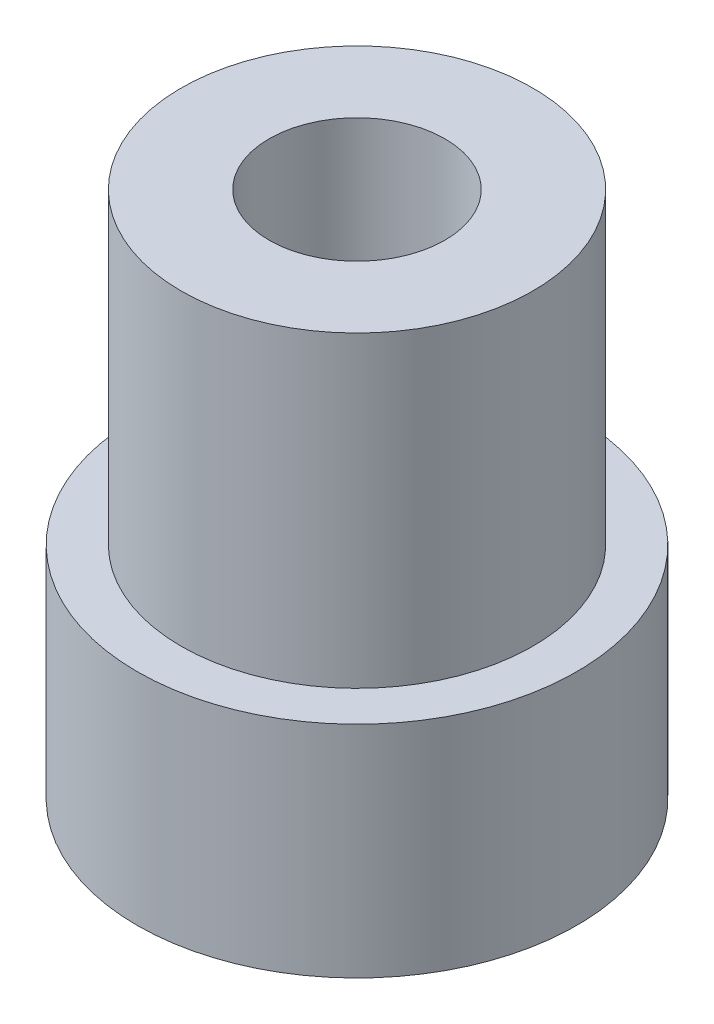
from build123d import *

# Parameters (mm, degrees)
SKETCH2_R           = 4
BOSS_EXTRUDE1_DEPTH = 7
SKETCH3_R           = 5
BOSS_EXTRUDE2_DEPTH = 5
SKETCH4_R           = 1.65
CUT_EXTRUDE1_DEPTH  = 12
SKETCH5_R           = 2
CUT_EXTRUDE2_DEPTH  = 5


with BuildPart() as part:
    # Sketch2 → Boss-Extrude1 (new body)
    with BuildSketch(Plane(origin=(0, 0, 0), x_dir=(1, 0, 0), z_dir=(0, 1, 0))):
        Circle(SKETCH2_R)
    extrude(amount=BOSS_EXTRUDE1_DEPTH)

    # Sketch3 → Boss-Extrude2 (add)
    with BuildSketch(Plane.XZ):
        Circle(SKETCH3_R)
    extrude(amount=BOSS_EXTRUDE2_DEPTH)

    # Sketch4 → Cut-Extrude1 (cut)
    with BuildSketch(Plane(origin=(0, 7, 0), x_dir=(1, 0, 0), z_dir=(0, 1, 0))):
        Circle(SKETCH4_R)
    extrude(amount=-CUT_EXTRUDE1_DEPTH, mode=Mode.SUBTRACT)

    # Sketch5 → Cut-Extrude2 (cut)
    with BuildSketch(Plane.XZ.offset(-7)):
        Circle(SKETCH5_R)
    extrude(amount=CUT_EXTRUDE2_DEPTH, mode=Mode.SUBTRACT)


solid = part.part
